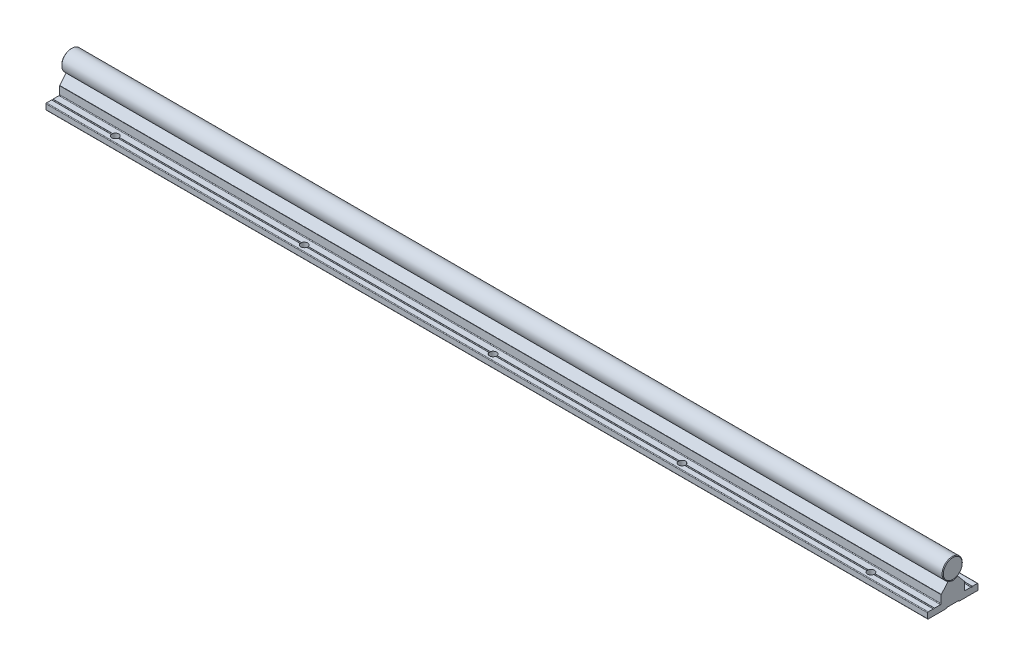
from build123d import *

# Parameters (mm, degrees)
EXTRUDE_4892_DEPTH     = 350
SKETCH_1_3_R           = 8
EXTRUDE_5022_DEPTH     = 350
FILLET_4_R             = 0.2
SKETCH_2_R             = 2.75
CUT_EXTRUDE_1_DEPTH    = 6
PATTERN_LINEAR_1_COUNT = 5
PATTERN_LINEAR_1_PITCH = 150
PATTERN_LINEAR_2_COUNT = 5
PATTERN_LINEAR_2_PITCH = 150
FILLET_1_R             = 0.3
CUT_EXTRUDE_2_DEPTH    = 3
FILLET_2_R             = 0.3
PATTERN_LINEAR_3_COUNT = 5
PATTERN_LINEAR_3_PITCH = 150
CHAMFER_1_SIZE         = 0.5
FILLET_3_R             = 0.5
FILLET_5_R             = 0.2
FILLET_6_R             = 0.1
FILLET_7_R             = 0.1


with BuildPart() as part:
    # Эскиз1 → Extrude 4892 (new body, symmetric)
    with BuildSketch(Plane(origin=(0, 0, 0), x_dir=(0, 0, -1), z_dir=(1, 0, 0))):
        Polygon((-20, -25), (-4.75, -25), (-4.75, -24.4), (4.75, -24.4), (4.75, -25), (20, -25), (20, -20), (15.5, -20), (15, -20.5), (14.5, -20), (9.25, -20), (9.25, -13.3), (9.110116754, -13.3), (4, -7.21), (3.8, -7.21), (2.309327639, -7.659439004), (0, -8.355703281), (-2.309327657, -7.659438999), (-3.8, -7.21), (-4, -7.21), (-9.110116754, -13.3), (-9.25, -13.3), (-9.25, -20), (-14.5, -20), (-15, -20.5), (-15.5, -20), (-20, -20), align=None)
    extrude(amount=EXTRUDE_4892_DEPTH, both=True)

    # Скругление4
    fillet_4_edges = [part.edges().sort_by_distance(p)[0] for p in [
        (0, -20, -15.5),
        (0, -24.4, -4.75),
        (0, -24.4, 4.75),
        (0, -20, 15.5),
        (0, -20, 14.5),
        (0, -8.355703281, 0),
        (0, -20, -14.5),
    ]]
    fillet(fillet_4_edges, radius=FILLET_4_R)

    # Эскиз2 → Вырез-Вытянуть1 (cut, through all)
    with BuildSketch(Plane(origin=(0, -20, 0), x_dir=(1, 0, 0), z_dir=(0, 1, 0))):
        with Locations((-300, -15)):
            Circle(SKETCH_2_R)
        with Locations((-300, 15)):
            Circle(SKETCH_2_R)
        with Locations((-150, -15)):
            Circle(SKETCH_2_R)
        with Locations((-150, 15)):
            Circle(SKETCH_2_R)
        with Locations((0, -15)):
            Circle(SKETCH_2_R)
        with Locations((0, 15)):
            Circle(SKETCH_2_R)
        with Locations((150, -15)):
            Circle(SKETCH_2_R)
        with Locations((150, 15)):
            Circle(SKETCH_2_R)
        with Locations((300, -15)):
            Circle(SKETCH_2_R)
        with Locations((300, 15)):
            Circle(SKETCH_2_R)
        with Locations((450, -15)):
            Circle(SKETCH_2_R)
        with Locations((450, 15)):
            Circle(SKETCH_2_R)
        with Locations((600, -15)):
            Circle(SKETCH_2_R)
        with Locations((600, 15)):
            Circle(SKETCH_2_R)
        with Locations((750, -15)):
            Circle(SKETCH_2_R)
        with Locations((750, 15)):
            Circle(SKETCH_2_R)
        with Locations((900, -15)):
            Circle(SKETCH_2_R)
        with Locations((900, 15)):
            Circle(SKETCH_2_R)
        with Locations((1050, -15)):
            Circle(SKETCH_2_R)
        with Locations((1050, 15)):
            Circle(SKETCH_2_R)
        with Locations((1200, -15)):
            Circle(SKETCH_2_R)
        with Locations((1200, 15)):
            Circle(SKETCH_2_R)
        with Locations((1350, -15)):
            Circle(SKETCH_2_R)
        with Locations((1350, 15)):
            Circle(SKETCH_2_R)
        with Locations((1500, -15)):
            Circle(SKETCH_2_R)
        with Locations((1500, 15)):
            Circle(SKETCH_2_R)
        with Locations((1650, -15)):
            Circle(SKETCH_2_R)
        with Locations((1650, 15)):
            Circle(SKETCH_2_R)
        with Locations((1800, -15)):
            Circle(SKETCH_2_R)
        with Locations((1800, 15)):
            Circle(SKETCH_2_R)
        with Locations((1950, -15)):
            Circle(SKETCH_2_R)
        with Locations((1950, 15)):
            Circle(SKETCH_2_R)
        with Locations((2100, -15)):
            Circle(SKETCH_2_R)
        with Locations((2100, 15)):
            Circle(SKETCH_2_R)
        with Locations((2250, -15)):
            Circle(SKETCH_2_R)
        with Locations((2250, 15)):
            Circle(SKETCH_2_R)
        with Locations((2400, -15)):
            Circle(SKETCH_2_R)
        with Locations((2400, 15)):
            Circle(SKETCH_2_R)
        with Locations((2550, -15)):
            Circle(SKETCH_2_R)
        with Locations((2550, 15)):
            Circle(SKETCH_2_R)
    extrude(amount=-CUT_EXTRUDE_1_DEPTH, mode=Mode.SUBTRACT)

    # Эскиз3 → Вырез-Повернуть1 (revolve, cut)
    with BuildSketch(Plane.XY):
        Polygon((-300, 0), (-302.2, -1.270170592), (-302.2, -7.5), (-302.75, -7.5), (-302.75, -19), (-304.75, -19), (-304.75, -24.4), (-300, -24.4), align=None)
    cut_revolve_1 = revolve(axis=Axis((-300, 56.434869358, 0), (0, -1, 0)), mode=Mode.SUBTRACT)

    # Линейный массив1: Вырез-Повернуть1 ×5
    with Locations(*[(i * PATTERN_LINEAR_1_PITCH, 0, 0) for i in range(1, PATTERN_LINEAR_1_COUNT)]):
        add(cut_revolve_1, mode=Mode.SUBTRACT)

    # Скругление3
    fillet_3_edges = [part.edges().sort_by_distance(p)[0] for p in [
        (0, -20, -9.25),
        (0, -20, -20),
        (0, -25, -20),
        (0, -25, -4.75),
        (0, -25, 4.75),
        (0, -20, 9.25),
        (0, -25, 20),
        (0, -20, 20),
    ]]
    fillet(fillet_3_edges, radius=FILLET_3_R)

    # Скругление5
    fillet_5_edges = [part.edges().sort_by_distance(p)[0] for p in [
        (0, -7.21, 4),
        (0, -7.21, 3.8),
        (0, -7.21, -3.8),
        (0, -7.21, -4),
    ]]
    fillet(fillet_5_edges, radius=FILLET_5_R)

    # Скругление6
    fillet_6_edges = [part.edges().sort_by_distance(p)[0] for p in [
        (0, -13.3, 9.25),
        (0, -13.3, -9.25),
    ]]
    fillet(fillet_6_edges, radius=FILLET_6_R)

    # Скругление7
    fillet_7_edges = [part.edges().sort_by_distance(p)[0] for p in [
        (0, -13.3, 9.110116754),
        (0, -13.3, -9.110116754),
    ]]
    fillet(fillet_7_edges, radius=FILLET_7_R)


with BuildPart() as body_2:
    # Эскиз1<3> → Extrude 5022 (new body, symmetric)
    with BuildSketch(Plane(origin=(0, 0, 0), x_dir=(0, 0, -1), z_dir=(1, 0, 0))):
        Circle(SKETCH_1_3_R)
    extrude(amount=EXTRUDE_5022_DEPTH, both=True)

    # Эскиз4 → Вырез-Повернуть2 (revolve, cut)
    with BuildSketch(Plane.XY):
        Polygon((-300, -10), (-302.2, -10), (-302.2, -1.270170592), (-300, 0), align=None)
    cut_revolve_2 = revolve(axis=Axis((-300, 39.840222878, 0), (0, -1, 0)), mode=Mode.SUBTRACT)

    # Линейный массив2: Вырез-Повернуть2 ×5
    with Locations(*[(i * PATTERN_LINEAR_2_PITCH, 0, 0) for i in range(1, PATTERN_LINEAR_2_COUNT)]):
        add(cut_revolve_2, mode=Mode.SUBTRACT)

    # Фаска1
    chamfer_1_edges = [body_2.edges().sort_by_distance(p)[0] for p in [
        (-350, 0, 8),
        (350, 0, 8),
    ]]
    chamfer(chamfer_1_edges, length=CHAMFER_1_SIZE)


with BuildPart() as body_3:
    # Эскиз5 → Повернуть1 (revolve)
    with BuildSketch(Plane.XY):
        Polygon((-300, -24), (-304.5, -24), (-304.5, -19), (-302.5, -19), (-302.5, -2.461880215), (-301.7, -2), (-300, -2), align=None)
    revolve(axis=Axis((-300, 35.529626596, 0), (0, -1, 0)))

    # Скругление1
    fillet_1_edges = [body_3.edges().sort_by_distance(p)[0] for p in [
        (-295.5, -19, 0),
    ]]
    fillet(fillet_1_edges, radius=FILLET_1_R)

    # Эскиз6 → Вырез-Вытянуть2 (cut)
    with BuildSketch(Plane.XZ.offset(24)):
        Polygon((-298.25, -1.010362971), (-298.25, 1.010362971), (-300, 2.020725942), (-301.75, 1.010362971), (-301.75, -1.010362971), (-300, -2.020725942), align=None)
    extrude(amount=-CUT_EXTRUDE_2_DEPTH, mode=Mode.SUBTRACT)

    # Скругление2
    fillet_2_edges = [body_3.edges().sort_by_distance(p)[0] for p in [
        (-299.125, -24, -1.515544457),
        (-298.25, -24, 0),
        (-299.125, -24, 1.515544457),
        (-300.875, -24, 1.515544457),
        (-301.75, -24, 0),
        (-300.875, -24, -1.515544457),
        (-295.5, -24, 0),
    ]]
    fillet(fillet_2_edges, radius=FILLET_2_R)


with BuildPart() as pattern_linear_3_1:
    # Линейный массив3: pattern copy
    add(body_3.part.moved(Location(Vector(1, 0, 0) * (1 * PATTERN_LINEAR_3_PITCH))))


with BuildPart() as pattern_linear_3_2:
    # Линейный массив3: pattern copy
    add(body_3.part.moved(Location(Vector(1, 0, 0) * (2 * PATTERN_LINEAR_3_PITCH))))


with BuildPart() as pattern_linear_3_3:
    # Линейный массив3: pattern copy
    add(body_3.part.moved(Location(Vector(1, 0, 0) * (3 * PATTERN_LINEAR_3_PITCH))))


with BuildPart() as pattern_linear_3_4:
    # Линейный массив3: pattern copy
    add(body_3.part.moved(Location(Vector(1, 0, 0) * (4 * PATTERN_LINEAR_3_PITCH))))


solid = Compound([part.part, body_2.part, body_3.part, pattern_linear_3_1.part, pattern_linear_3_2.part, pattern_linear_3_3.part, pattern_linear_3_4.part])
